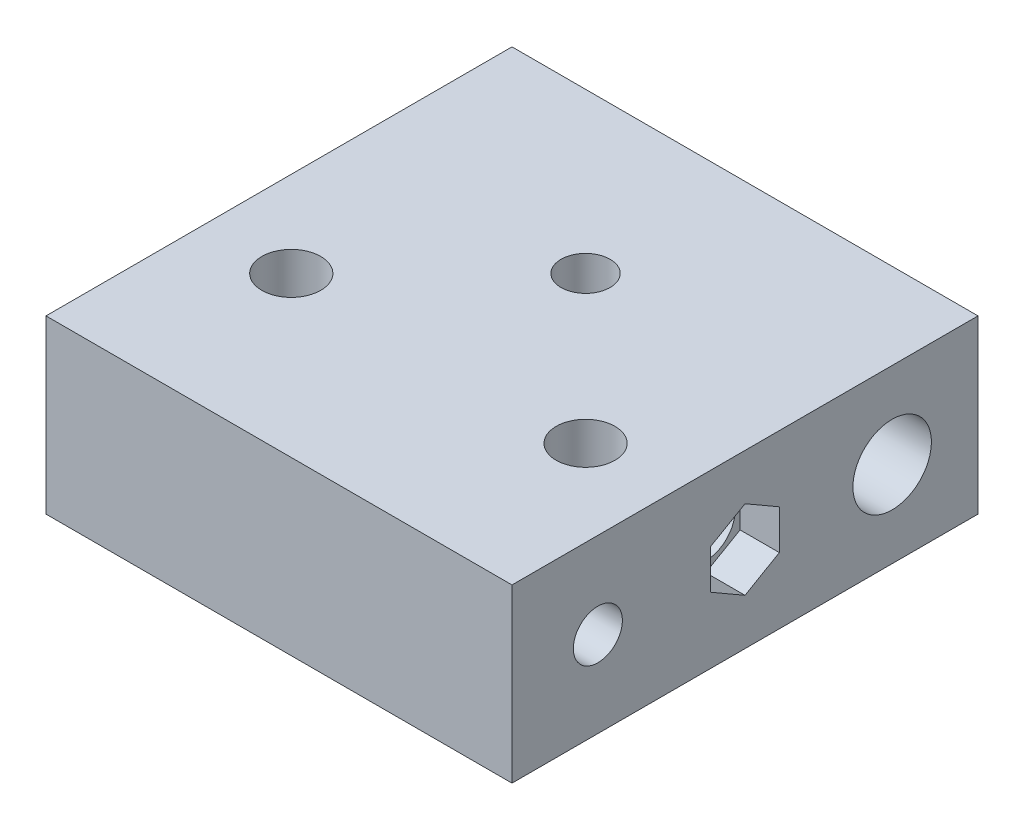
from build123d import *

# Parameters (mm, degrees)
SKETCH1_W           = 95
SKETCH1_H           = 35
BOSS_EXTRUDE1_DEPTH = 95
SKETCH2_R           = 5
SKETCH2_R_2         = 6
CUT_EXTRUDE1_DEPTH  = 95
SKETCH3_R           = 8
CUT_EXTRUDE2_DEPTH  = 26
SKETCH4_R           = 8
CUT_EXTRUDE3_DEPTH  = 60
SKETCH5_R           = 8
CUT_EXTRUDE4_DEPTH  = 26
SKETCH6_R           = 5
SKETCH6_R_2         = 6
CUT_EXTRUDE5_DEPTH  = 35
SKETCH8_R           = 8
CUT_EXTRUDE7_DEPTH  = 26
CUT_EXTRUDE10_DEPTH = 8
CUT_EXTRUDE14_DEPTH = 8
CUT_EXTRUDE15_DEPTH = 8


with BuildPart() as part:
    # Sketch1 → Boss-Extrude1 (new body)
    with BuildSketch(Plane.XY):
        Rectangle(SKETCH1_W, SKETCH1_H)
    extrude(amount=BOSS_EXTRUDE1_DEPTH)

    # Sketch2 → Cut-Extrude1 (cut)
    with BuildSketch(Plane.ZY.offset(47.5)):
        with Locations(Location((17.5, 0, 0), (0, 0, 270))):  # turned: the seam where the file's is
            Circle(SKETCH2_R)
        with Locations(Location((47.5, 0, 0), (0, 0, 270))):  # turned: the seam where the file's is
            Circle(SKETCH2_R_2)
        with Locations(Location((77.5, 0, 0), (0, 0, 270))):  # turned: the seam where the file's is
            Circle(SKETCH2_R)
    extrude(amount=-CUT_EXTRUDE1_DEPTH, mode=Mode.SUBTRACT)

    # Sketch3 → Cut-Extrude2 (cut)
    with BuildSketch(Plane.ZY.offset(47.5)):
        with Locations(Location((17.5, 0, 0), (0, 0, 270))):  # turned: the seam where the file's is
            Circle(SKETCH3_R)
    extrude(amount=-CUT_EXTRUDE2_DEPTH, mode=Mode.SUBTRACT)

    # Sketch4 → Cut-Extrude3 (cut)
    with BuildSketch(Plane.ZY.offset(47.5)):
        with Locations(Location((77.5, 0, 0), (0, 0, 270))):  # turned: the seam where the file's is
            Circle(SKETCH4_R)
    extrude(amount=-CUT_EXTRUDE3_DEPTH, mode=Mode.SUBTRACT)

    # Sketch5 → Cut-Extrude4 (cut)
    with BuildSketch(Plane(origin=(47.5, 0, 0), x_dir=(0, 0, -1), z_dir=(1, 0, 0))):
        with Locations(Location((-17.5, 0, 0), (0, 0, 270))):  # turned: the seam where the file's is
            Circle(SKETCH5_R)
    extrude(amount=-CUT_EXTRUDE4_DEPTH, mode=Mode.SUBTRACT)

    # Sketch6 → Cut-Extrude5 (cut)
    with BuildSketch(Plane(origin=(0, 17.5, 0), x_dir=(1, 0, 0), z_dir=(0, 1, 0))):
        with Locations(Location((0, -32.5, 0), (0, 0, 90))):  # turned: the seam where the file's is
            Circle(SKETCH6_R)
        with Locations(Location((-30, -62.5, 0), (0, 0, 90))):  # turned: the seam where the file's is
            Circle(SKETCH6_R_2)
        with Locations(Location((30, -62.5, 0), (0, 0, 90))):  # turned: the seam where the file's is
            Circle(SKETCH6_R_2)
    extrude(amount=-CUT_EXTRUDE5_DEPTH, mode=Mode.SUBTRACT)

    # Sketch8 → Cut-Extrude7 (cut)
    with BuildSketch(Plane.XZ.offset(17.5)):
        with Locations(Location((30, 62.5, 0), (0, 0, 270))):  # turned: the seam where the file's is
            Circle(SKETCH8_R)
    extrude(amount=-CUT_EXTRUDE7_DEPTH, mode=Mode.SUBTRACT)

    # Sketch12 → Cut-Extrude10 (cut)
    with BuildSketch(Plane.XZ.offset(17.5)):
        Polygon((8.082903769, 32.5), (4.041451884, 39.5), (-4.041451884, 39.5), (-8.082903769, 32.5), (-4.041451884, 25.5), (4.041451884, 25.5), align=None)
    extrude(amount=-CUT_EXTRUDE10_DEPTH, mode=Mode.SUBTRACT)

    # Sketch16 → Cut-Extrude14 (cut)
    with BuildSketch(Plane.ZY.offset(47.5)):
        Polygon((47.5, -8.082903769), (54.5, -4.041451884), (54.5, 4.041451884), (47.5, 8.082903769), (40.5, 4.041451884), (40.5, -4.041451884), align=None)
    extrude(amount=-CUT_EXTRUDE14_DEPTH, mode=Mode.SUBTRACT)

    # Sketch17 → Cut-Extrude15 (cut)
    with BuildSketch(Plane(origin=(47.5, 0, 0), x_dir=(0, 0, -1), z_dir=(1, 0, 0))):
        Polygon((-47.5, -8.082903769), (-40.5, -4.041451884), (-40.5, 4.041451884), (-47.5, 8.082903769), (-54.5, 4.041451884), (-54.5, -4.041451884), align=None)
    extrude(amount=-CUT_EXTRUDE15_DEPTH, mode=Mode.SUBTRACT)


solid = part.part
